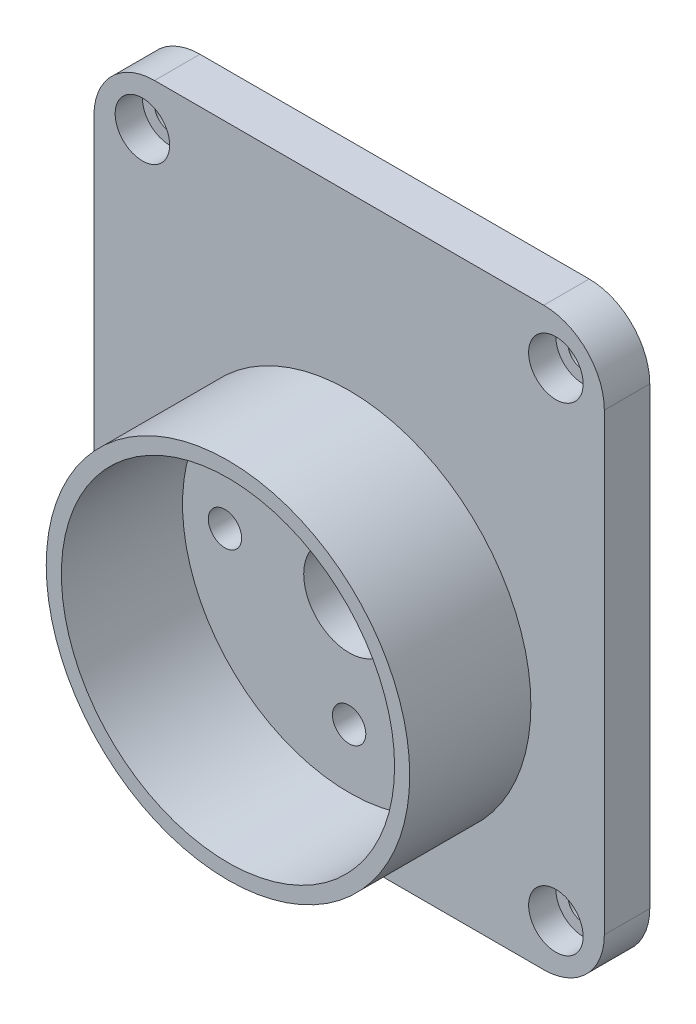
from build123d import *

# Parameters (mm, degrees)
SZKIC1_R                    = 3
SZKIC1_R_2                  = 1.1
SZKIC1_R_3                  = 1
DODANIE_WYCI_GNI_CIE1_DEPTH = 3
SZKIC2_R                    = 12
SZKIC2_R_2                  = 11
DODANIE_WYCI_GNI_CIE2_DEPTH = 8
SZKIC3_R                    = 1.1
SZKIC3_R_2                  = 3
WYTNIJ_WYCI_GNI_CIE1_DEPTH  = 1
SZKIC4_R                    = 1.8
WYTNIJ_WYCI_GNI_CIE2_DEPTH  = 1.8
ZAOKR_GLENIE1_R             = 4


with BuildPart() as part:
    # Szkic1 → Dodanie-wyciągnięcie1 (new body)
    with BuildSketch(Plane.XY):
        Polygon((-16.85, 0), (-16.85, -14.7), (0, -14.7), (16.85, -14.7), (16.85, 23.3), (-16.85, 23.3), align=None)
        Circle(SZKIC1_R, mode=Mode.SUBTRACT)
        with Locations((-8.2, 0)):
            Circle(SZKIC1_R_2, mode=Mode.SUBTRACT)
        with Locations((8.2, 0)):
            Circle(SZKIC1_R_2, mode=Mode.SUBTRACT)
        with Locations((0, 7.1)):
            Circle(SZKIC1_R_2, mode=Mode.SUBTRACT)
        with Locations((0, -7.1)):
            Circle(SZKIC1_R_2, mode=Mode.SUBTRACT)
        with Locations((-13.65, 20.1)):
            Circle(SZKIC1_R_3, mode=Mode.SUBTRACT)
        with Locations((13.65, 20.1)):
            Circle(SZKIC1_R_3, mode=Mode.SUBTRACT)
        with Locations((13.65, -11.5)):
            Circle(SZKIC1_R_3, mode=Mode.SUBTRACT)
        with Locations((-13.65, -11.5)):
            Circle(SZKIC1_R_3, mode=Mode.SUBTRACT)
    extrude(amount=DODANIE_WYCI_GNI_CIE1_DEPTH)

    # Szkic2 → Dodanie-wyciągnięcie2 (add)
    with BuildSketch(Plane.XY.offset(3)):
        Circle(SZKIC2_R)
        Circle(SZKIC2_R_2, mode=Mode.SUBTRACT)
    extrude(amount=DODANIE_WYCI_GNI_CIE2_DEPTH)

    # Szkic3 → Wytnij-wyciągnięcie1 (cut)
    with BuildSketch(Plane(origin=(0, 0, 0), x_dir=(-1, 0, 0), z_dir=(0, 0, -1))):
        with BuildLine():
            Line((11.326209992, 22.3), (-11.326209992, 22.3))
            ThreePointArc((-11.326209992, 22.3), (-10.67711184, 21.284033778), (-10.45, 20.1))
            ThreePointArc((-10.45, 20.1), (-12.385088936, 17.160612309), (-15.85, 17.776209992))
            Line((-15.85, 17.776209992), (-15.85, -9.176209992))
            ThreePointArc((-15.85, -9.176209992), (-12.385088936, -8.560612309), (-10.45, -11.5))
            ThreePointArc((-10.45, -11.5), (-10.67711184, -12.684033778), (-11.326209992, -13.7))
            Line((-11.326209992, -13.7), (11.326209992, -13.7))
            ThreePointArc((11.326209992, -13.7), (11.3872583, -9.2372583), (15.85, -9.176209992))
            Line((15.85, -9.176209992), (15.85, 17.776209992))
            ThreePointArc((15.85, 17.776209992), (11.3872583, 17.8372583), (11.326209992, 22.3))
        make_face()
        with Locations((-8.2, 0)):
            Circle(SZKIC3_R, mode=Mode.SUBTRACT)
        with Locations((0, -7.1)):
            Circle(SZKIC3_R, mode=Mode.SUBTRACT)
        Circle(SZKIC3_R_2, mode=Mode.SUBTRACT)
        with Locations((8.2, 0)):
            Circle(SZKIC3_R, mode=Mode.SUBTRACT)
        with Locations((0, 7.1)):
            Circle(SZKIC3_R, mode=Mode.SUBTRACT)
    extrude(amount=-WYTNIJ_WYCI_GNI_CIE1_DEPTH, mode=Mode.SUBTRACT)

    # Szkic4 → Wytnij-wyciągnięcie2 (cut)
    with BuildSketch(Plane.XY.offset(3)):
        with Locations((-13.65, 20.1)):
            Circle(SZKIC4_R)
        with Locations((13.65, 20.1)):
            Circle(SZKIC4_R)
        with Locations((13.65, -11.5)):
            Circle(SZKIC4_R)
        with Locations((-13.65, -11.5)):
            Circle(SZKIC4_R)
    extrude(amount=-WYTNIJ_WYCI_GNI_CIE2_DEPTH, mode=Mode.SUBTRACT)

    # Zaokrąglenie1
    zaokr_glenie1_edges = [part.edges().sort_by_distance(p)[0] for p in [
        (-16.85, 23.3, 1.5),
        (16.85, 23.3, 1.5),
        (16.85, -14.7, 1.5),
        (-16.85, -14.7, 1.5),
    ]]
    fillet(zaokr_glenie1_edges, radius=ZAOKR_GLENIE1_R)


solid = part.part
